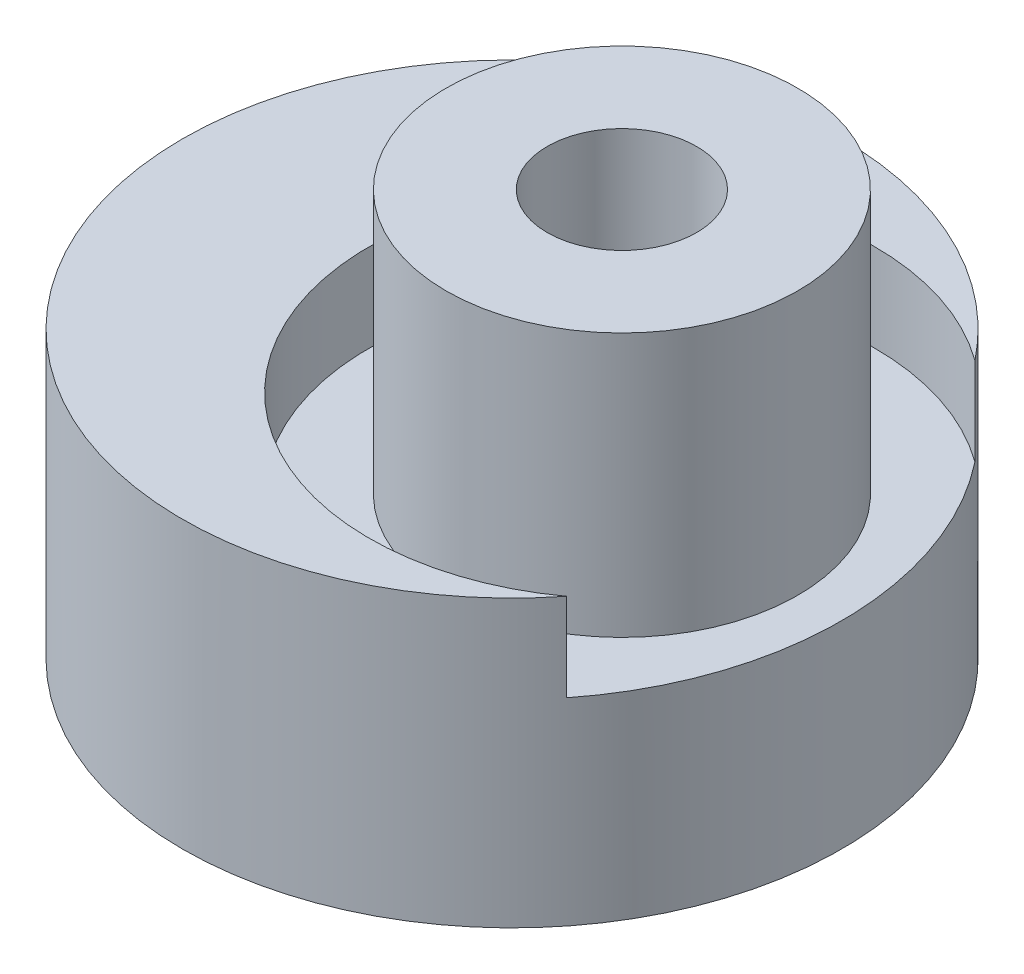
from build123d import *

# Parameters (mm, degrees)
SKETCH_1_R          = 7.5
SKETCH_1_R_2        = 3
EXTRUDE_1_DEPTH     = 3
SKETCH_2_R          = 7.5
SKETCH_2_R_2        = 1.8
EXTRUDE_2_DEPTH     = 3.5
SKETCH_3_R          = 5.75
SKETCH_3_R_2        = 4
CUT_EXTRUDE_1_DEPTH = 2
SKETCH_4_R          = 4
SKETCH_4_R_2        = 1.7
EXTRUDE_3_DEPTH     = 4
SKETCH_5_R          = 3
CUT_EXTRUDE_2_DEPTH = 3.5
CHAMFER_1_SIZE      = 0.6


with BuildPart() as part:
    # Эскиз1 → Бобышка-Вытянуть1 (new body)
    with BuildSketch(Plane(origin=(0, 0, 0), x_dir=(1, 0, 0), z_dir=(0, 1, 0))):
        with Locations((-2.5, 0)):
            Circle(SKETCH_1_R)
        Circle(SKETCH_1_R_2, mode=Mode.SUBTRACT)
    extrude(amount=EXTRUDE_1_DEPTH)

    # Эскиз2 → Бобышка-Вытянуть2 (add)
    with BuildSketch(Plane(origin=(0, 3, 0), x_dir=(1, 0, 0), z_dir=(0, 1, 0))):
        with Locations((-2.5, 0)):
            Circle(SKETCH_2_R)
        Circle(SKETCH_2_R_2, mode=Mode.SUBTRACT)
    extrude(amount=EXTRUDE_2_DEPTH)

    # Эскиз3 → Вырез-Вытянуть1 (cut)
    with BuildSketch(Plane(origin=(0, 6.5, 0), x_dir=(1, 0, 0), z_dir=(0, 1, 0))):
        Circle(SKETCH_3_R)
        Circle(SKETCH_3_R_2, mode=Mode.SUBTRACT)
    extrude(amount=-CUT_EXTRUDE_1_DEPTH, mode=Mode.SUBTRACT)

    # Эскиз4 → Бобышка-Вытянуть3 (add)
    with BuildSketch(Plane(origin=(0, 6.5, 0), x_dir=(1, 0, 0), z_dir=(0, 1, 0))):
        Circle(SKETCH_4_R)
        Circle(SKETCH_4_R_2, mode=Mode.SUBTRACT)
    extrude(amount=EXTRUDE_3_DEPTH)

    # Эскиз5 → Вырез-Вытянуть2 (cut)
    with BuildSketch(Plane.XZ):
        Circle(SKETCH_5_R)
    extrude(amount=-CUT_EXTRUDE_2_DEPTH, mode=Mode.SUBTRACT)

    # Фаска1
    chamfer_1_edges = [part.edges().sort_by_distance(p)[0] for p in [
        (-3, 0, 0),
    ]]
    chamfer(chamfer_1_edges, length=CHAMFER_1_SIZE)


solid = part.part
